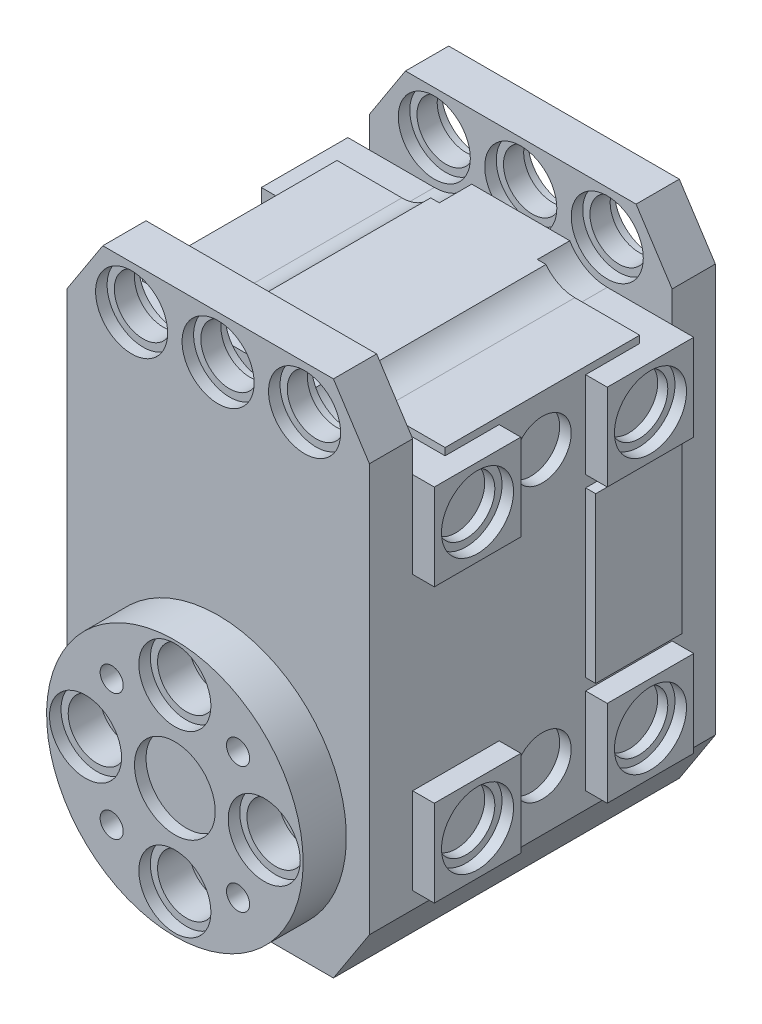
from build123d import *

# Parameters (mm, degrees)
BOSS_EXTRUDE1_DEPTH     = 12
SKETCH2_R               = 8.9
SKETCH2_R_2             = 2
SKETCH2_R_3             = 0.8
BOSS_EXTRUDE2_DEPTH     = 3
SKETCH4_R               = 2.5
SKETCH4_R_2             = 2.8
CUT_EXTRUDE1_DEPTH      = 0.8
SKETCH9_R               = 2
CUT_EXTRUDE4_DEPTH      = 3
SKETCH10_R              = 2.5
CUT_EXTRUDE5_DEPTH      = 0.8
MIRROR3_COPY_1_SKETCH_R = 2.5
MIRROR3_COPY_1_DEPTH    = 0.8
CUT_EXTRUDE3_DEPTH      = 9
SKETCH5_W               = 6
SKETCH5_H               = 6
SKETCH5_R               = 2
SKETCH5_H_2             = 11.4
BOSS_EXTRUDE3_DEPTH     = 1.5
SKETCH6_R               = 2.5
SKETCH6_W               = 6
SKETCH6_H               = 11.4
CUT_EXTRUDE2_DEPTH      = 0.8
SKETCH11_R              = 2
CUT_EXTRUDE6_DEPTH      = 0.8
CUT_EXTRUDE7_DEPTH      = 2.25
SKETCH13_R              = 2
CUT_EXTRUDE8_DEPTH      = 3
SKETCH14_R              = 2.5
CUT_EXTRUDE9_DEPTH      = 0.8


with BuildPart() as part:
    # Sketch1 → Boss-Extrude1 (new body, symmetric)
    with BuildSketch(Plane.XY):
        Polygon((8, 18), (-8, 18), (-10.5, 14.15), (-10.5, -14.15), (-8, -18), (8, -18), (10.5, -14.15), (10.5, 14.15), align=None)
    extrude(amount=BOSS_EXTRUDE1_DEPTH, both=True)

    # Sketch2 → Boss-Extrude2 (add)
    with BuildSketch(Plane.XY.offset(12)):
        with Locations((0, -9.1)):
            Circle(SKETCH2_R)
        with Locations((0, -15.3)):
            Circle(SKETCH2_R_2, mode=Mode.SUBTRACT)
        with Locations((-4.384062043, -13.484062043)):
            Circle(SKETCH2_R_3, mode=Mode.SUBTRACT)
        with Locations((4.384062043, -13.484062043)):
            Circle(SKETCH2_R_3, mode=Mode.SUBTRACT)
        with Locations((6.2, -9.1)):
            Circle(SKETCH2_R_2, mode=Mode.SUBTRACT)
        with Locations((4.384062043, -4.715937957)):
            Circle(SKETCH2_R_3, mode=Mode.SUBTRACT)
        with Locations((0, -2.9)):
            Circle(SKETCH2_R_2, mode=Mode.SUBTRACT)
        with Locations((-4.384062043, -4.715937957)):
            Circle(SKETCH2_R_3, mode=Mode.SUBTRACT)
        with Locations((-6.2, -9.1)):
            Circle(SKETCH2_R_2, mode=Mode.SUBTRACT)
    extrude(amount=BOSS_EXTRUDE2_DEPTH)

    # Sketch4 → Cut-Extrude1 (cut)
    with BuildSketch(Plane.XY.offset(15)):
        with Locations((0, -15.3)):
            Circle(SKETCH4_R)
        with Locations((0, -2.9)):
            Circle(SKETCH4_R)
        with Locations((-6.2, -9.1)):
            Circle(SKETCH4_R)
        with Locations((6.2, -9.1)):
            Circle(SKETCH4_R)
        with Locations((0, -9.1)):
            Circle(SKETCH4_R_2)
    extrude(amount=-CUT_EXTRUDE1_DEPTH, mode=Mode.SUBTRACT)

    # Sketch9 → Cut-Extrude4 (cut)
    with BuildSketch(Plane.XY.offset(12)):
        with Locations((0, 15)):
            Circle(SKETCH9_R)
        with Locations((6, 15)):
            Circle(SKETCH9_R)
        with Locations((-6, 15)):
            Circle(SKETCH9_R)
    cut_extrude4 = extrude(amount=-CUT_EXTRUDE4_DEPTH, mode=Mode.SUBTRACT)

    # Sketch10 → Cut-Extrude5 (cut)
    with BuildSketch(Plane.XY.offset(12)):
        with Locations((0, 15)):
            Circle(SKETCH10_R)
        with Locations((6, 15)):
            Circle(SKETCH10_R)
        with Locations((-6, 15)):
            Circle(SKETCH10_R)
    cut_extrude5 = extrude(amount=-CUT_EXTRUDE5_DEPTH, mode=Mode.SUBTRACT)

    # Mirror2: Cut-Extrude5 across plane
    add(cut_extrude5.mirror(Plane.XY.offset(10.5)), mode=Mode.SUBTRACT)

    # Mirror3: Cut-Extrude4, Cut-Extrude5 across plane
    add(cut_extrude4.mirror(Plane.XY), mode=Mode.SUBTRACT)
    add(cut_extrude5.mirror(Plane.XY), mode=Mode.SUBTRACT)

    # Mirror3 copy 1 sketch → Mirror3 copy 1 (cut)
    with BuildSketch(Plane.XY.offset(-9)):
        with Locations((0, 15)):
            Circle(MIRROR3_COPY_1_SKETCH_R)
        with Locations((6, 15)):
            Circle(MIRROR3_COPY_1_SKETCH_R)
        with Locations((-6, 15)):
            Circle(MIRROR3_COPY_1_SKETCH_R)
    extrude(amount=-MIRROR3_COPY_1_DEPTH, mode=Mode.SUBTRACT)

    # Sketch8 → Cut-Extrude3 (cut, symmetric)
    with BuildSketch(Plane.XY):
        with BuildLine():
            Line((8, 18), (-8, 18))
            Line((-8, 18), (-10.5, 14.15))
            Line((-10.5, 14.15), (-10.5, 12.5))
            Line((-10.5, 12.5), (-6, 12.5))
            ThreePointArc((-6, 12.5), (-4.881966011, 12.763932023), (-4, 13.5))
            Line((-4, 13.5), (4, 13.5))
            ThreePointArc((4, 13.5), (4.881966011, 12.763932023), (6, 12.5))
            Line((6, 12.5), (10.5, 12.5))
            Line((10.5, 12.5), (10.5, 14.15))
            Line((10.5, 14.15), (8, 18))
        make_face()
    extrude(amount=CUT_EXTRUDE3_DEPTH, both=True, mode=Mode.SUBTRACT)

    # Sketch5 → Boss-Extrude3 (add)
    with BuildSketch(Plane(origin=(10.5, 0, 0), x_dir=(0, 0, -1), z_dir=(1, 0, 0))):
        with Locations((-6, -10)):
            Rectangle(SKETCH5_W, SKETCH5_H)
        with Locations((-6, -10)):
            Circle(SKETCH5_R, mode=Mode.SUBTRACT)
        with Locations((6, -0.5)):
            Rectangle(SKETCH5_W, SKETCH5_H_2)
        with Locations((-6, 9)):
            Rectangle(SKETCH5_W, SKETCH5_H)
        with Locations((-6, 9)):
            Circle(SKETCH5_R, mode=Mode.SUBTRACT)
        with Locations((6, 9)):
            Rectangle(SKETCH5_W, SKETCH5_H)
        with Locations((6, 9)):
            Circle(SKETCH5_R, mode=Mode.SUBTRACT)
        with Locations((6, -10)):
            Rectangle(SKETCH5_W, SKETCH5_H)
        with Locations((6, -10)):
            Circle(SKETCH5_R, mode=Mode.SUBTRACT)
    boss_extrude3 = extrude(amount=BOSS_EXTRUDE3_DEPTH)

    # Sketch6 → Cut-Extrude2 (cut)
    with BuildSketch(Plane(origin=(12, 0, 0), x_dir=(0, 0, -1), z_dir=(1, 0, 0))):
        with Locations((-6, -10)):
            Circle(SKETCH6_R)
        with Locations((-6, 9)):
            Circle(SKETCH6_R)
        with Locations((6, 9)):
            Circle(SKETCH6_R)
        with Locations((6, -10)):
            Circle(SKETCH6_R)
        with Locations((6, -0.5)):
            Rectangle(SKETCH6_W, SKETCH6_H)
    cut_extrude2 = extrude(amount=-CUT_EXTRUDE2_DEPTH, mode=Mode.SUBTRACT)

    # Sketch11 → Cut-Extrude6 (cut)
    with BuildSketch(Plane(origin=(10.5, 0, 0), x_dir=(0, 0, -1), z_dir=(1, 0, 0))):
        with Locations((0, 9)):
            Circle(SKETCH11_R)
        with Locations((0, -10)):
            Circle(SKETCH11_R)
    cut_extrude6 = extrude(amount=-CUT_EXTRUDE6_DEPTH, mode=Mode.SUBTRACT)

    # Mirror4: Boss-Extrude3, Cut-Extrude2, Cut-Extrude6 across plane
    add(boss_extrude3.mirror(Plane(origin=(0, 0, 0), x_dir=(0, 0, 1), z_dir=(1, 0, 0))))
    add(cut_extrude2.mirror(Plane(origin=(0, 0, 0), x_dir=(0, 0, 1), z_dir=(1, 0, 0))), mode=Mode.SUBTRACT)
    add(cut_extrude6.mirror(Plane(origin=(0, 0, 0), x_dir=(0, 0, 1), z_dir=(1, 0, 0))), mode=Mode.SUBTRACT)

    # Sketch12 → Cut-Extrude7 (cut)
    with BuildSketch(Plane(origin=(0, 0, 9), x_dir=(-1, 0, 0), z_dir=(0, 0, -1))):
        with BuildLine():
            Line((-6, 12.5), (-10.5, 12.5))
            Line((-10.5, 12.5), (-10.5, 12))
            Line((-10.5, 12), (-6, 12))
            ThreePointArc((-6, 12), (-4.5, 12.401923789), (-3.401923789, 13.5))
            Line((-3.401923789, 13.5), (-4, 13.5))
            ThreePointArc((-4, 13.5), (-4.881966011, 12.763932023), (-6, 12.5))
        make_face()
        with BuildLine():
            Line((3.401923789, 13.5), (4, 13.5))
            ThreePointArc((4, 13.5), (4.881966011, 12.763932023), (6, 12.5))
            Line((6, 12.5), (10.5, 12.5))
            Line((10.5, 12.5), (10.5, 12))
            Line((10.5, 12), (6, 12))
            ThreePointArc((6, 12), (4.5, 12.401923789), (3.401923789, 13.5))
        make_face()
    cut_extrude7 = extrude(amount=CUT_EXTRUDE7_DEPTH, mode=Mode.SUBTRACT)

    # Mirror5: Cut-Extrude7 across plane
    add(cut_extrude7.mirror(Plane.XY), mode=Mode.SUBTRACT)

    # Sketch13 → Cut-Extrude8 (cut)
    with BuildSketch(Plane(origin=(0, 0, -12), x_dir=(-1, 0, 0), z_dir=(0, 0, -1))):
        with Locations((0, -9.1)):
            Circle(SKETCH13_R)
        with Locations((6, -9.1)):
            Circle(SKETCH13_R)
        with Locations((-6, -9.1)):
            Circle(SKETCH13_R)
    extrude(amount=-CUT_EXTRUDE8_DEPTH, mode=Mode.SUBTRACT)

    # Sketch14 → Cut-Extrude9 (cut)
    with BuildSketch(Plane(origin=(0, 0, -12), x_dir=(-1, 0, 0), z_dir=(0, 0, -1))):
        with Locations((0, -9.1)):
            Circle(SKETCH14_R)
        with Locations((6, -9.1)):
            Circle(SKETCH14_R)
        with Locations((-6, -9.1)):
            Circle(SKETCH14_R)
    extrude(amount=-CUT_EXTRUDE9_DEPTH, mode=Mode.SUBTRACT)


solid = part.part
